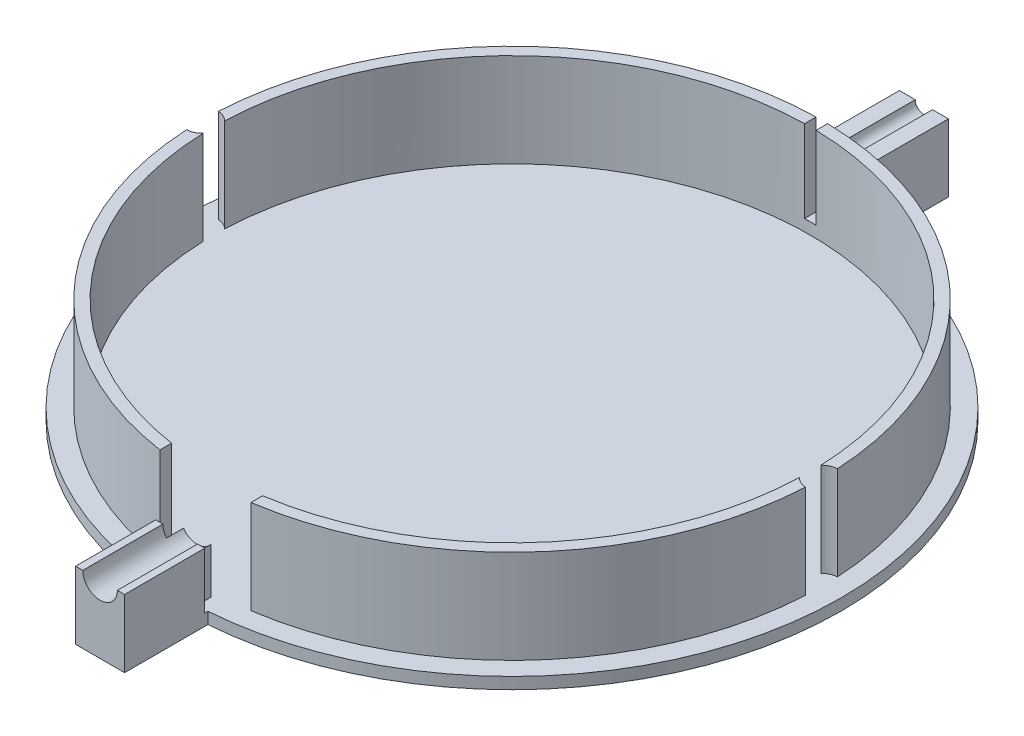
from build123d import *

# Parameters (mm, degrees)
SKETCH1_R                = 57.15
BOSS_EXTRUDE1_DEPTH      = 2
SKETCH2_R                = 53.75
SKETCH2_R_2              = 51.75
BOSS_EXTRUDE2_DEPTH      = 16.25
CUT_EXTRUDE1_DEPTH       = 16.25
CUT_EXTRUDE2_DEPTH       = 6.8
BOSS_EXTRUDE5_DEPTH      = 16.25
CUT_EXTRUDE3_DEPTH       = 7.6
SKETCH9_W                = 2
SKETCH9_H                = 2
SKETCH9_H_2              = 12.25
CUT_EXTRUDE4_DEPTH       = 58.15
CUT_EXTRUDE5_DEPTH       = 16.25
SKETCH12_W               = 4.25
SKETCH12_H               = 14.29
SKETCH12_R               = 57.15
BOSS_EXTRUDE7_DEPTH      = 2
BOSS_EXTRUDE8_DEPTH      = 13.9
BOSS_EXTRUDE9_DEPTH      = 2
BOSS_EXTRUDE9_DEPTH_BACK = 2
BOSS_EXTRUDE10_DEPTH     = 13.9


with BuildPart() as part:
    # Sketch1 → Boss-Extrude1 (new body)
    with BuildSketch(Plane(origin=(0, 0, 0), x_dir=(1, 0, 0), z_dir=(0, 1, 0))):
        Circle(SKETCH1_R)
    extrude(amount=BOSS_EXTRUDE1_DEPTH)

    # Sketch2 → Boss-Extrude2 (add)
    with BuildSketch(Plane(origin=(0, 2, 0), x_dir=(1, 0, 0), z_dir=(0, 1, 0))):
        Circle(SKETCH2_R)
        Circle(SKETCH2_R_2, mode=Mode.SUBTRACT)
    extrude(amount=BOSS_EXTRUDE2_DEPTH)

    # Sketch4 → Cut-Extrude1 (cut)
    with BuildSketch(Plane(origin=(0, 18.25, 0), x_dir=(1, 0, 0), z_dir=(0, 1, 0))):
        with BuildLine():
            ThreePointArc((51.75, 0), (51.741714453, -0.926005111), (51.716860465, -1.851713701))
            ThreePointArc((51.716860465, -1.851713701), (52.606544101, -2.501001521), (53.679651163, -2.749100042))
            ThreePointArc((53.679651163, -2.749100042), (53.732409912, -1.375), (53.75, 0))
            ThreePointArc((53.75, 0), (53.732409912, 1.375), (53.679651163, 2.749100042))
            ThreePointArc((53.679651163, 2.749100042), (52.606544101, 2.501001521), (51.716860465, 1.851713701))
            ThreePointArc((51.716860465, 1.851713701), (51.741714453, 0.926005111), (51.75, 0))
        make_face()
        with BuildLine():
            ThreePointArc((-51.716860465, 1.851713701), (-51.75, 0), (-51.716860465, -1.851713701))
            ThreePointArc((-51.716860465, -1.851713701), (-52.606544101, -2.501001521), (-53.679651163, -2.749100042))
            ThreePointArc((-53.679651163, -2.749100042), (-53.75, 0), (-53.679651163, 2.749100042))
            ThreePointArc((-53.679651163, 2.749100042), (-52.606544101, 2.501001521), (-51.716860465, 1.851713701))
        make_face()
    extrude(amount=-CUT_EXTRUDE1_DEPTH, mode=Mode.SUBTRACT)

    # Sketch5 → Cut-Extrude2 (cut)
    with BuildSketch(Plane(origin=(0, 18.25, 0), x_dir=(1, 0, 0), z_dir=(0, 1, 0))):
        with BuildLine():
            Line((0, -53.75), (0, -51.75))
            ThreePointArc((0, -51.75), (-1.500631048, -51.728237999), (-3, -51.662970298))
            Line((-3, -51.662970298), (-3, -53.666213766))
            ThreePointArc((-3, -53.666213766), (-1.500584897, -53.729049358), (0, -53.75))
        make_face()
        with BuildLine():
            ThreePointArc((3, -51.662970298), (1.500631048, -51.728237999), (0, -51.75))
            Line((0, -51.75), (0, -53.75))
            ThreePointArc((0, -53.75), (1.500584897, -53.729049358), (3, -53.666213766))
            Line((3, -53.666213766), (3, -51.662970298))
        make_face()
    extrude(amount=-CUT_EXTRUDE2_DEPTH, mode=Mode.SUBTRACT)

    # Sketch7 → Boss-Extrude5 (add)
    with BuildSketch(Plane(origin=(0, 2, 0), x_dir=(1, 0, 0), z_dir=(0, 1, 0))):
        with BuildLine():
            Line((2.4, -54.571141496), (2.4, -57.099584062))
            ThreePointArc((2.4, -57.099584062), (0, -57.15), (-2.4, -57.099584062))
            Line((-2.4, -57.099584062), (-2.4, -54.571141496))
            ThreePointArc((-2.4, -54.571141496), (0, -54.623891148), (2.4, -54.571141496))
        make_face()
    extrude(amount=BOSS_EXTRUDE5_DEPTH)

    # Sketch8 → Cut-Extrude3 (cut)
    with BuildSketch(Plane.XY.offset(57.15)):
        with BuildLine():
            Line((2.4, 11.75), (2.4, 13.55))
            ThreePointArc((2.4, 13.55), (0, 14.75), (-2.4, 13.55))
            Line((-2.4, 13.55), (-2.4, 11.75))
            Line((-2.4, 11.75), (2.4, 11.75))
        make_face()
        with BuildLine():
            Line((2.4, 9.95), (2.4, 11.75))
            Line((2.4, 11.75), (-2.4, 11.75))
            Line((-2.4, 11.75), (-2.4, 9.95))
            ThreePointArc((-2.4, 9.95), (0, 8.75), (2.4, 9.95))
        make_face()
        with BuildLine():
            Line((2.4, 11.75), (2.4, 13.55))
            ThreePointArc((2.4, 13.55), (0, 14.75), (-2.4, 13.55))
            Line((-2.4, 13.55), (-2.4, 11.75))
            Line((-2.4, 11.75), (2.4, 11.75))
        make_face()
        with BuildLine():
            Line((2.4, 9.95), (2.4, 11.75))
            Line((2.4, 11.75), (-2.4, 11.75))
            Line((-2.4, 11.75), (-2.4, 9.95))
            ThreePointArc((-2.4, 9.95), (0, 8.75), (2.4, 9.95))
        make_face()
        with BuildLine():
            Line((2.4, 13.55), (2.4, 18.25))
            Line((2.4, 18.25), (-2.4, 18.25))
            Line((-2.4, 18.25), (-2.4, 13.55))
            ThreePointArc((-2.4, 13.55), (0, 14.75), (2.4, 13.55))
        make_face()
        with BuildLine():
            ThreePointArc((3, 11.75), (2.846049894, 12.698683298), (2.4, 13.55))
            Line((2.4, 13.55), (2.4, 11.75))
            Line((2.4, 11.75), (2.4, 9.95))
            ThreePointArc((2.4, 9.95), (2.846049894, 10.801316702), (3, 11.75))
        make_face()
        with BuildLine():
            Line((-2.4, 11.75), (-2.4, 13.55))
            ThreePointArc((-2.4, 13.55), (-3, 11.75), (-2.4, 9.95))
            Line((-2.4, 9.95), (-2.4, 11.75))
        make_face()
    extrude(amount=-CUT_EXTRUDE3_DEPTH, mode=Mode.SUBTRACT)

    # Sketch9 → Cut-Extrude4 (cut, through all)
    with BuildSketch(Plane.XY):
        with Locations((0, 5)):
            Rectangle(SKETCH9_W, SKETCH9_H)
        with Locations((0, 12.125)):
            Rectangle(SKETCH9_W, SKETCH9_H_2)
    extrude(amount=-CUT_EXTRUDE4_DEPTH, mode=Mode.SUBTRACT)

    # Sketch11 → Cut-Extrude5 (cut)
    with BuildSketch(Plane(origin=(0, 18.25, 0), x_dir=(1, 0, 0), z_dir=(0, 1, 0))):
        with BuildLine():
            Line((7.9, -53.166272203), (7.9, -51.143450216))
            ThreePointArc((7.9, -51.143450216), (5.456186881, -51.461563567), (3, -51.662970298))
            Line((3, -51.662970298), (3, -53.666213766))
            ThreePointArc((3, -53.666213766), (5.455729593, -53.472399559), (7.9, -53.166272203))
        make_face()
        with BuildLine():
            ThreePointArc((-3, -51.662970298), (-5.456186881, -51.461563567), (-7.9, -51.143450216))
            Line((-7.9, -51.143450216), (-7.9, -53.166272203))
            ThreePointArc((-7.9, -53.166272203), (-5.455729593, -53.472399559), (-3, -53.666213766))
            Line((-3, -53.666213766), (-3, -51.662970298))
        make_face()
        with BuildLine():
            Line((7.9, -51.143450216), (7.9, -49.368739918))
            Line((7.9, -49.368739918), (-7.9, -49.368739918))
            Line((-7.9, -49.368739918), (-7.9, -51.143450216))
            ThreePointArc((-7.9, -51.143450216), (-5.456186881, -51.461563567), (-3, -51.662970298))
            Line((-3, -51.662970298), (-3, -53.666213766))
            ThreePointArc((-3, -53.666213766), (-5.455729593, -53.472399559), (-7.9, -53.166272203))
            Line((-7.9, -53.166272203), (-7.9, -53.957200677))
            Line((-7.9, -53.957200677), (7.9, -53.957200677))
            Line((7.9, -53.957200677), (7.9, -53.166272203))
            ThreePointArc((7.9, -53.166272203), (5.455729593, -53.472399559), (3, -53.666213766))
            Line((3, -53.666213766), (3, -51.662970298))
            ThreePointArc((3, -51.662970298), (5.456186881, -51.461563567), (7.9, -51.143450216))
        make_face()
    extrude(amount=-CUT_EXTRUDE5_DEPTH, mode=Mode.SUBTRACT)

    # Sketch12 → Boss-Extrude7 (add)
    with BuildSketch(Plane.XZ):
        with Locations((2.125, 64.295)):
            Rectangle(SKETCH12_W, SKETCH12_H)
        with Locations((-2.125, 64.295)):
            Rectangle(SKETCH12_W, SKETCH12_H)
        with BuildLine():
            Line((4.25, 57.15), (0, 57.15))
            ThreePointArc((0, 57.15), (2.126472541, 57.110424745), (4.25, 56.991753789))
            Line((4.25, 56.991753789), (4.25, 57.15))
        make_face()
        with BuildLine():
            ThreePointArc((-4.25, 56.991753789), (-2.126472541, 57.110424745), (0, 57.15))
            Line((0, 57.15), (-4.25, 57.15))
            Line((-4.25, 57.15), (-4.25, 56.991753789))
        make_face()
        with Locations((2.125, -64.295)):
            Rectangle(SKETCH12_W, SKETCH12_H)
        with Locations((-2.125, -64.295)):
            Rectangle(SKETCH12_W, SKETCH12_H)
        with BuildLine():
            ThreePointArc((0, -57.15), (-2.126472541, -57.110424745), (-4.25, -56.991753789))
            Line((-4.25, -56.991753789), (-4.25, -57.15))
            Line((-4.25, -57.15), (0, -57.15))
        make_face()
        with BuildLine():
            Line((4.25, -57.15), (4.25, -56.991753789))
            ThreePointArc((4.25, -56.991753789), (2.126472541, -57.110424745), (0, -57.15))
            Line((0, -57.15), (4.25, -57.15))
        make_face()
        Circle(SKETCH12_R)
    extrude(amount=-BOSS_EXTRUDE7_DEPTH)

    # Sketch13 → Boss-Extrude8 (add)
    with BuildSketch(Plane.XY.offset(71.44)):
        with BuildLine():
            Line((-3, 11.75), (-4.25, 11.75))
            Line((-4.25, 11.75), (-4.25, 2))
            Line((-4.25, 2), (4.25, 2))
            Line((4.25, 2), (4.25, 11.75))
            Line((4.25, 11.75), (3, 11.75))
            ThreePointArc((3, 11.75), (0, 8.75), (-3, 11.75))
        make_face()
    extrude(amount=-BOSS_EXTRUDE8_DEPTH)

    # Sketch14 → Boss-Extrude9 (add, two sides)
    with BuildSketch(Plane.XY.offset(57.15)) as boss_extrude9_sk:
        with BuildLine():
            Line((-2.4, 2), (2.4, 2))
            Line((2.4, 2), (2.4, 9.95))
            ThreePointArc((2.4, 9.95), (0, 8.75), (-2.4, 9.95))
            Line((-2.4, 9.95), (-2.4, 2))
        make_face()
    extrude(amount=BOSS_EXTRUDE9_DEPTH)
    extrude(boss_extrude9_sk.sketch, amount=-BOSS_EXTRUDE9_DEPTH_BACK)

    # Sketch15 → Boss-Extrude10 (add)
    with BuildSketch(Plane(origin=(0, 0, -71.44), x_dir=(-1, 0, 0), z_dir=(0, 0, -1))):
        with BuildLine():
            Line((-1.5, 11.75), (-4.25, 11.75))
            Line((-4.25, 11.75), (-4.25, 0))
            Line((-4.25, 0), (4.25, 0))
            Line((4.25, 0), (4.25, 11.75))
            Line((4.25, 11.75), (1.5, 11.75))
            ThreePointArc((1.5, 11.75), (0, 10.25), (-1.5, 11.75))
        make_face()
    extrude(amount=-BOSS_EXTRUDE10_DEPTH)


solid = part.part
